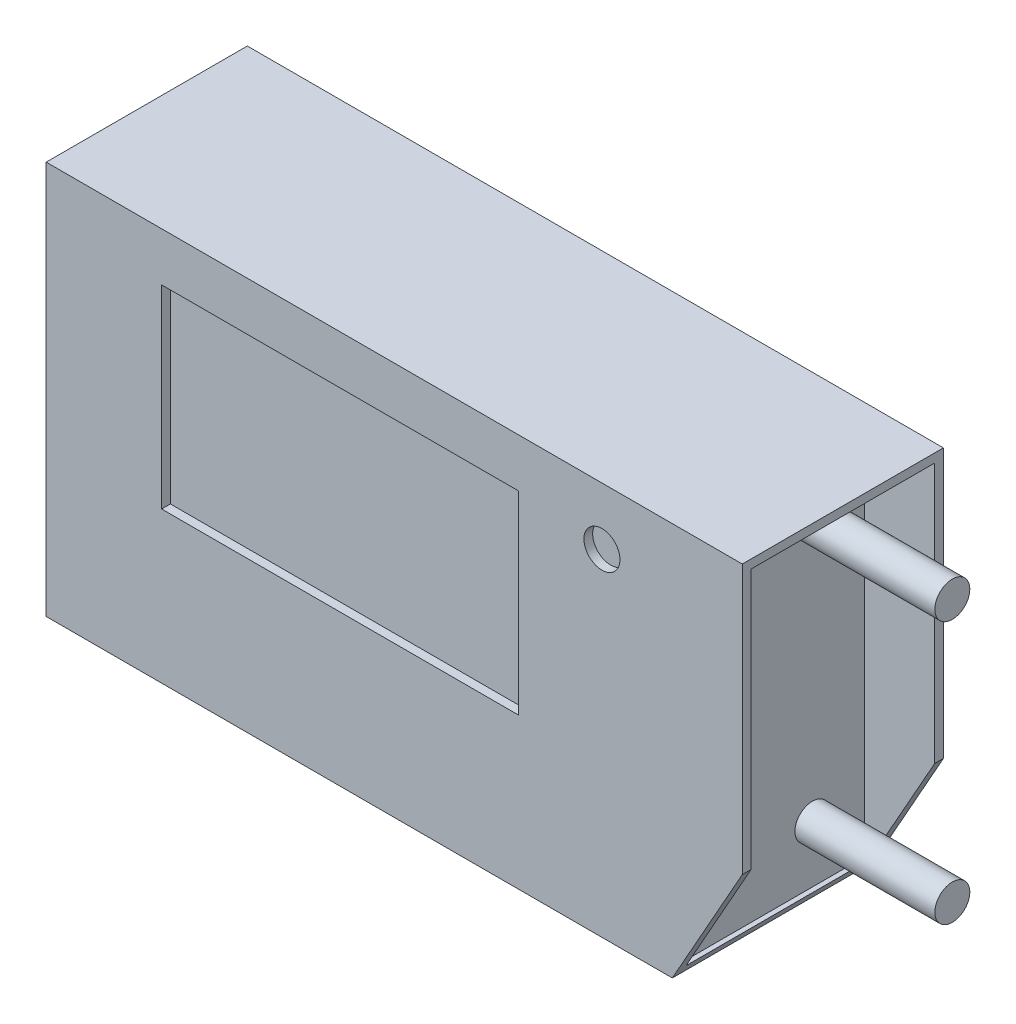
from build123d import *

# Parameters (mm, degrees)
SKETCH1_W           = 42
SKETCH1_H           = 22.5
BOSS_EXTRUDE1_DEPTH = 5.75
SKETCH2_W           = 10.5
SKETCH2_H           = 21.5
CUT_EXTRUDE1_DEPTH  = 4
CUT_EXTRUDE3_DEPTH  = 12.5
SKETCH8_W           = 2.2
SKETCH8_H           = 22.5
CUT_EXTRUDE4_DEPTH  = 12.5
SKETCH3_R           = 1
BOSS_EXTRUDE2_DEPTH = 8
SKETCH4_R           = 0.5
BOSS_EXTRUDE3_DEPTH = 8
SKETCH5_R           = 1.030633651
SKETCH5_W           = 20.392034512
SKETCH5_H           = 11.098868447
CUT_EXTRUDE2_DEPTH  = 0.5


with BuildPart() as part:
    # Sketch1 → Boss-Extrude1 (new body, symmetric)
    with BuildSketch(Plane.XY):
        Rectangle(SKETCH1_W, SKETCH1_H)
    extrude(amount=BOSS_EXTRUDE1_DEPTH, both=True)

    # Sketch2 → Cut-Extrude1 (cut)
    with BuildSketch(Plane(origin=(21, 0, 0), x_dir=(0, 0, -1), z_dir=(1, 0, 0))):
        Rectangle(SKETCH2_W, SKETCH2_H)
    cut_extrude1 = extrude(amount=-CUT_EXTRUDE1_DEPTH, mode=Mode.SUBTRACT)

    # Mirror1: Cut-Extrude1 across plane
    add(cut_extrude1.mirror(Plane(origin=(0, 0, 0), x_dir=(0, 0, 1), z_dir=(1, 0, 0))), mode=Mode.SUBTRACT)

    # Sketch7 → Cut-Extrude3 (cut, through all)
    with BuildSketch(Plane.XY.offset(-5.75)):
        Polygon((24.167892902, -4.130649904), (21, -4.130649904), (17, -11.25), (17, -14.180704283), (24.167892902, -14.180704283), align=None)
    extrude(amount=CUT_EXTRUDE3_DEPTH, mode=Mode.SUBTRACT)

    # Sketch8 → Cut-Extrude4 (cut, through all)
    with BuildSketch(Plane.XY.offset(5.75)):
        with Locations((-19.9, 0)):
            Rectangle(SKETCH8_W, SKETCH8_H)
    extrude(amount=-CUT_EXTRUDE4_DEPTH, mode=Mode.SUBTRACT)

    # Sketch3 → Boss-Extrude2 (add)
    with BuildSketch(Plane(origin=(17, 0, 0), x_dir=(0, 0, -1), z_dir=(1, 0, 0))):
        with Locations((2.259944465, 7.5)):
            Circle(SKETCH3_R)
        with Locations((2.259944465, -7.5)):
            Circle(SKETCH3_R)
    extrude(amount=BOSS_EXTRUDE2_DEPTH)

    # Sketch4 → Boss-Extrude3 (add)
    with BuildSketch(Plane.ZY.offset(17)):
        with Locations((-3.364806204, 2.988148793)):
            Circle(SKETCH4_R)
        with Locations((-3.364806204, -2.988148793)):
            Circle(SKETCH4_R)
    extrude(amount=BOSS_EXTRUDE3_DEPTH)

    # Sketch5 → Cut-Extrude2 (cut)
    with BuildSketch(Plane.XY.offset(5.75)):
        with Locations((12.976825893, 7.964601522)):
            Circle(SKETCH5_R)
        with Locations((-2.003815564, 2.9231166)):
            Rectangle(SKETCH5_W, SKETCH5_H)
    extrude(amount=-CUT_EXTRUDE2_DEPTH, mode=Mode.SUBTRACT)


solid = part.part
